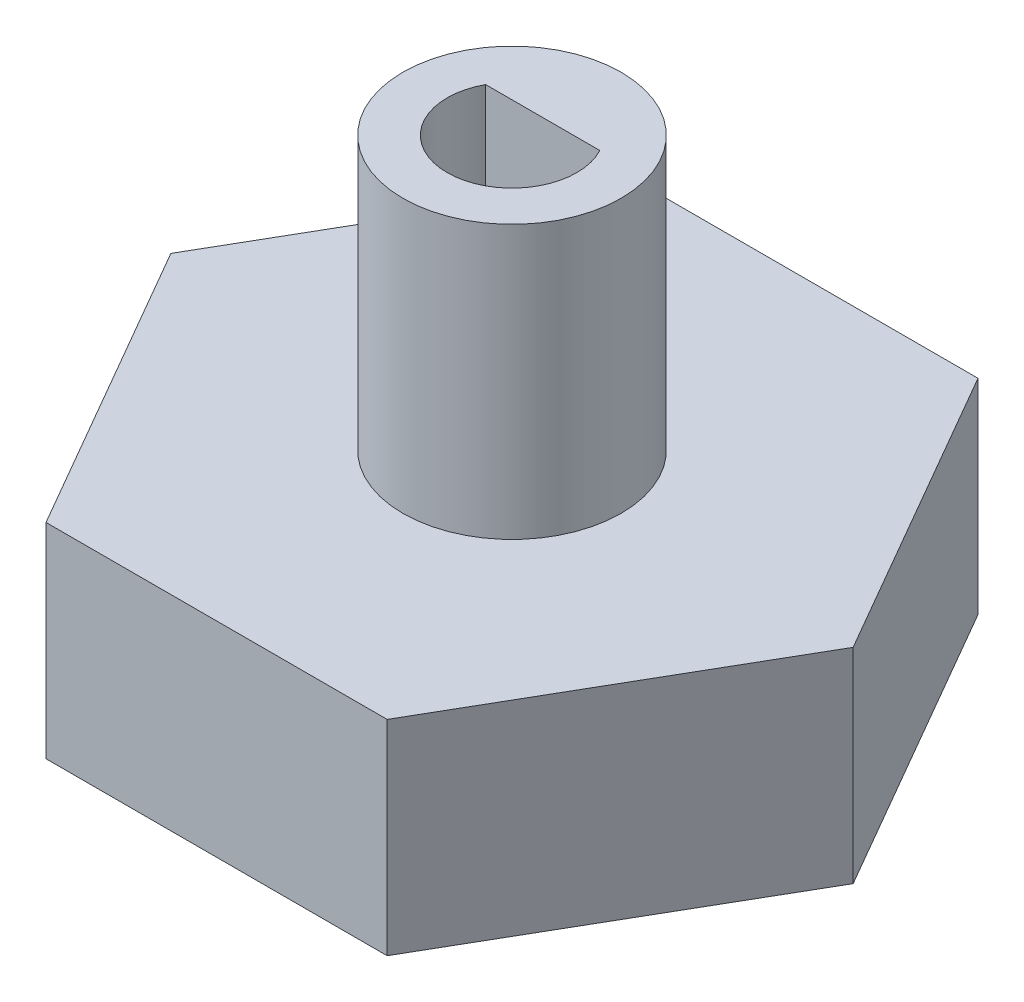
from build123d import *

# Parameters (mm, degrees)
BOSS_EXTRUDE1_DEPTH = 3.81
SKETCH2_R           = 2.032
BOSS_EXTRUDE2_DEPTH = 5.08
CUT_EXTRUDE1_DEPTH  = 9.89


with BuildPart() as part:
    # Sketch1 → Boss-Extrude1 (new body)
    with BuildSketch(Plane(origin=(0, 0, 0), x_dir=(1, 0, 0), z_dir=(0, 1, 0))):
        Polygon((6.35, 0), (3.175, 5.499261314), (-3.175, 5.499261314), (-6.35, 0), (-3.175, -5.499261314), (3.175, -5.499261314), align=None)
    extrude(amount=BOSS_EXTRUDE1_DEPTH)

    # Sketch2 → Boss-Extrude2 (add)
    with BuildSketch(Plane(origin=(0, 3.81, 0), x_dir=(1, 0, 0), z_dir=(0, 1, 0))):
        Circle(SKETCH2_R)
    extrude(amount=BOSS_EXTRUDE2_DEPTH)

    # Sketch3 → Cut-Extrude1 (cut, through all)
    with BuildSketch(Plane.XZ):
        with BuildLine():
            Line((-1.062558234, -0.5715), (1.062558234, -0.5715))
            ThreePointArc((1.062558234, -0.5715), (0, 1.2065), (-1.062558234, -0.5715))
        make_face()
    extrude(amount=-CUT_EXTRUDE1_DEPTH, mode=Mode.SUBTRACT)


solid = part.part
